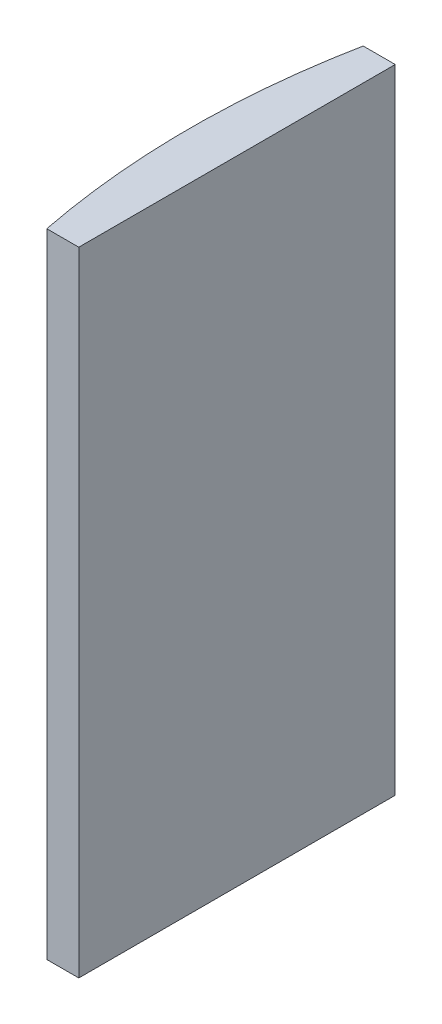
from build123d import *

# Parameters (mm, degrees)
EXTRUDE_1_DEPTH = 60


with BuildPart() as part:
    # 草图1 → 凸台-拉伸1 (new body)
    with BuildSketch(Plane(origin=(0, 0, 0), x_dir=(1, 0, 0), z_dir=(0, 1, 0))):
        with BuildLine():
            Line((-71.730290341, 15), (-68.694795665, 15))
            Line((-68.694795665, 15), (-68.694795665, -15))
            Line((-68.694795665, -15), (-71.730290341, -15))
            ThreePointArc((-71.730290341, -15), (-73.194795665, 0), (-71.730290341, 15))
        make_face()
    extrude(amount=EXTRUDE_1_DEPTH)


solid = part.part
